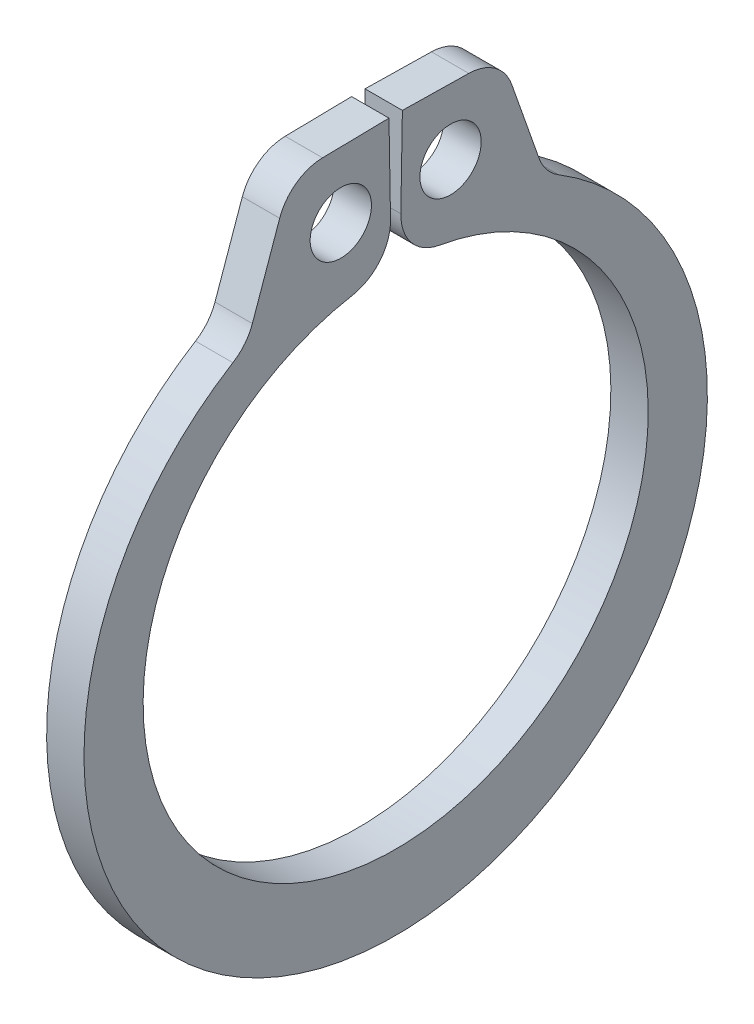
from build123d import *

# Parameters (mm, degrees)
SKETCH3_R                = 0.5207
BOSS_EXTRUDE1_DEPTH      = 0.3175
BOSS_EXTRUDE1_DEPTH_BACK = 0.3175
FILLET1_R                = 0.7874


with BuildPart() as part:
    # Sketch3 → Boss-Extrude1 (new body, two sides)
    with BuildSketch(Plane(origin=(0, 0, 0), x_dir=(0, 0, -1), z_dir=(1, 0, 0))) as boss_extrude1_sk:
        with BuildLine():
            Line((-1.790070495, 6.49754857), (-2.532309488, 4.3891842))
            ThreePointArc((-2.532309488, 4.3891842), (0, -5.5626), (2.532309488, 4.3891842))
            Line((2.532309488, 4.3891842), (1.790070495, 6.49754857))
            Line((1.790070495, 6.49754857), (0.113925819, 6.526805784))
            Line((0.113925819, 6.526805784), (0.0749162, 4.291946216))
            ThreePointArc((0.0749162, 4.291946216), (0, -4.2926), (-0.0749162, 4.291946216))
            Line((-0.0749162, 4.291946216), (-0.113925819, 6.526805784))
            Line((-0.113925819, 6.526805784), (-1.790070495, 6.49754857))
        make_face()
        with Locations((-0.932493347, 5.394747393)):
            Circle(SKETCH3_R, mode=Mode.SUBTRACT)
        with Locations((0.932493347, 5.394747393)):
            Circle(SKETCH3_R, mode=Mode.SUBTRACT)
    extrude(amount=BOSS_EXTRUDE1_DEPTH)
    extrude(boss_extrude1_sk.sketch, amount=-BOSS_EXTRUDE1_DEPTH_BACK)

    # Fillet1
    fillet1_edges = [part.edges().sort_by_distance(p)[0] for p in [
        (0, 4.3891842, 2.532309488),
        (0, 6.49754857, 1.790070495),
        (0, 4.291946216, 0.0749162),
        (0, 4.291946216, -0.0749162),
        (0, 6.49754857, -1.790070495),
        (0, 4.3891842, -2.532309488),
    ]]
    fillet(fillet1_edges, radius=FILLET1_R)


solid = part.part
